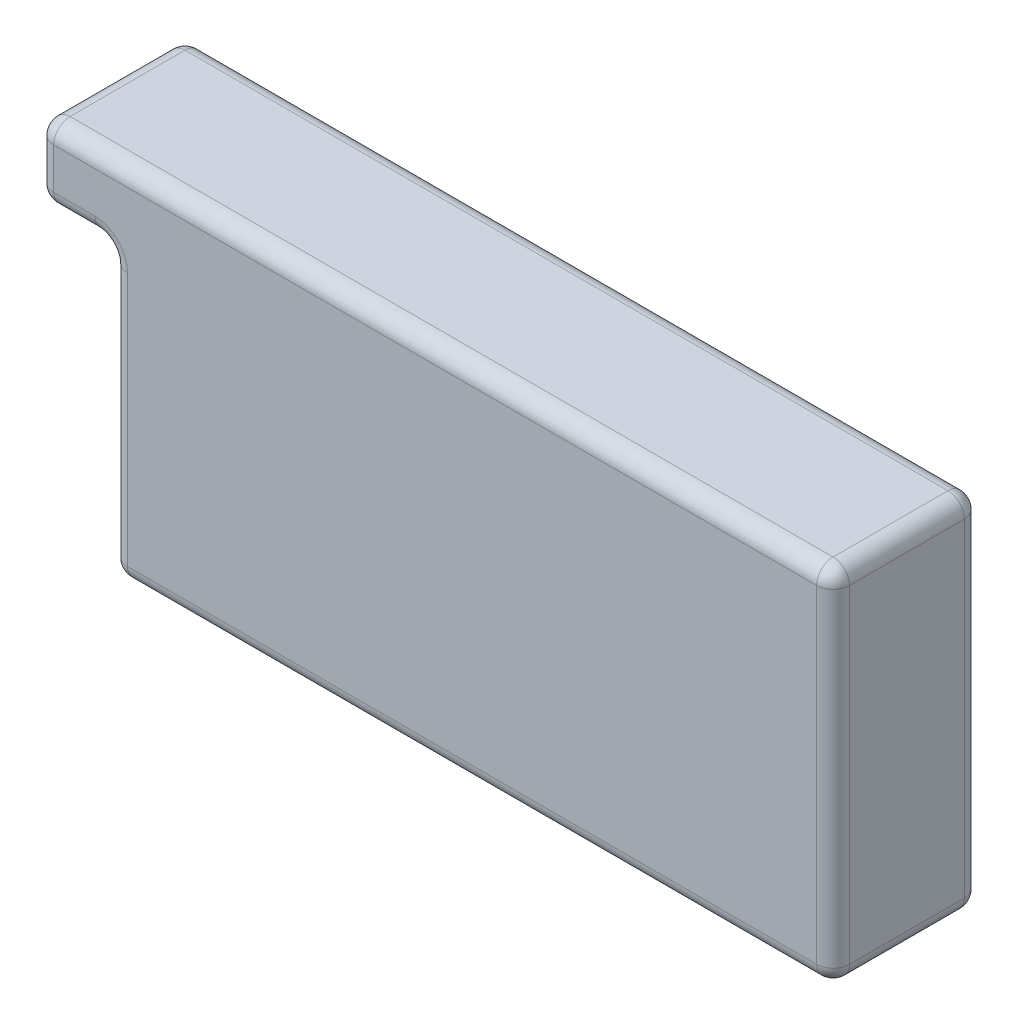
from build123d import *

# Parameters (mm, degrees)
ESQUISSE1_W             = 44
ESQUISSE1_H             = 22
BOSS_EXTRU_1_DEPTH      = 9
ESQUISSE2_W             = 9
ESQUISSE2_H             = 4.5
BOSS_EXTRU_2_DEPTH      = 4.5
BOSS_EXTRU_2_DEPTH_BACK = 9
CONG_2_R                = 1


with BuildPart() as part:
    # Esquisse1 → Boss.-Extru.1 (new body)
    with BuildSketch(Plane.XY):
        with Locations((22, -11)):
            Rectangle(ESQUISSE1_W, ESQUISSE1_H)
    extrude(amount=BOSS_EXTRU_1_DEPTH)

    # Esquisse2 → Boss.-Extru.2 (add, two sides)
    with BuildSketch(Plane.ZY) as boss_extru_2_sk:
        with Locations((4.5, -2.25)):
            Rectangle(ESQUISSE2_W, ESQUISSE2_H)
    extrude(amount=BOSS_EXTRU_2_DEPTH)
    extrude(boss_extru_2_sk.sketch, amount=-BOSS_EXTRU_2_DEPTH_BACK)

    # Congé2
    cong_2_edges = [part.edges().sort_by_distance(p)[0] for p in [
        (44, -11, 9),
        (19.75, 0, 9),
        (0, -13.25, 0),
        (0, -13.25, 9),
        (-2.25, -4.5, 0),
        (-2.25, -4.5, 9),
        (0, -4.5, 4.5),
        (-4.5, -2.25, 9),
        (-4.5, 0, 4.5),
        (-4.5, -2.25, 0),
        (-4.5, -4.5, 4.5),
        (19.75, 0, 0),
        (44, -11, 0),
        (22, -22, 0),
        (22, -22, 9),
        (44, 0, 4.5),
        (44, -22, 4.5),
        (0, -22, 4.5),
    ]]
    fillet(cong_2_edges, radius=CONG_2_R)


solid = part.part
